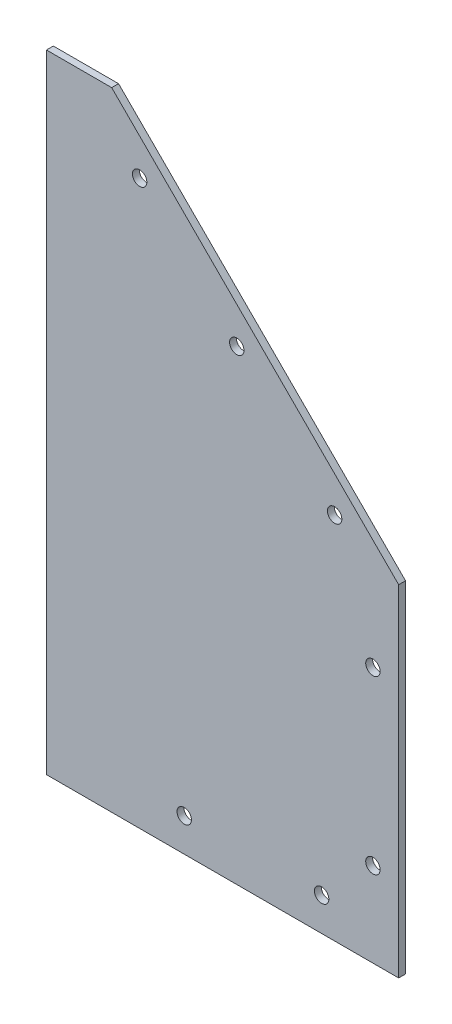
from build123d import *

# Parameters (mm, degrees)
SKETCH_1_R          = 2.1
EXTRUDE_1_DEPTH     = 2
SKETCH_2_R          = 2.1
CUT_EXTRUDE_1_DEPTH = 10
SKETCH_3_W          = 2
SKETCH_3_H          = 182.73
EXTRUDE_2_DEPTH     = 19


with BuildPart() as part:
    # ｽｹｯﾁ1 → ﾎﾞｽ - 押し出し1 (new body)
    with BuildSketch(Plane.XY):
        Polygon((0, 0), (0, 182.73), (83.56, 99.17), (83.56, 0), align=None)
        with Locations((8.132919651, 163.990478631)):
            Circle(SKETCH_1_R, mode=Mode.SUBTRACT)
        with Locations((36.417190898, 135.706207384)):
            Circle(SKETCH_1_R, mode=Mode.SUBTRACT)
        with Locations((64.91002614, 107.428490375)):
            Circle(SKETCH_1_R, mode=Mode.SUBTRACT)
        with Locations((76.06, 74.59)):
            Circle(SKETCH_1_R, mode=Mode.SUBTRACT)
        with Locations((76.06, 24.59)):
            Circle(SKETCH_1_R, mode=Mode.SUBTRACT)
    extrude(amount=EXTRUDE_1_DEPTH)

    # ｽｹｯﾁ2 → ｶｯﾄ - 押し出し1 (cut)
    with BuildSketch(Plane.XY.offset(2)):
        with Locations((21.12, 9.69)):
            Circle(SKETCH_2_R)
        with Locations((61.12, 9.69)):
            Circle(SKETCH_2_R)
    extrude(amount=-CUT_EXTRUDE_1_DEPTH, mode=Mode.SUBTRACT)

    # ｽｹｯﾁ3 → ﾎﾞｽ - 押し出し2 (add)
    with BuildSketch(Plane.ZY):
        with Locations((1, 91.365)):
            Rectangle(SKETCH_3_W, SKETCH_3_H)
    extrude(amount=EXTRUDE_2_DEPTH)


solid = part.part
